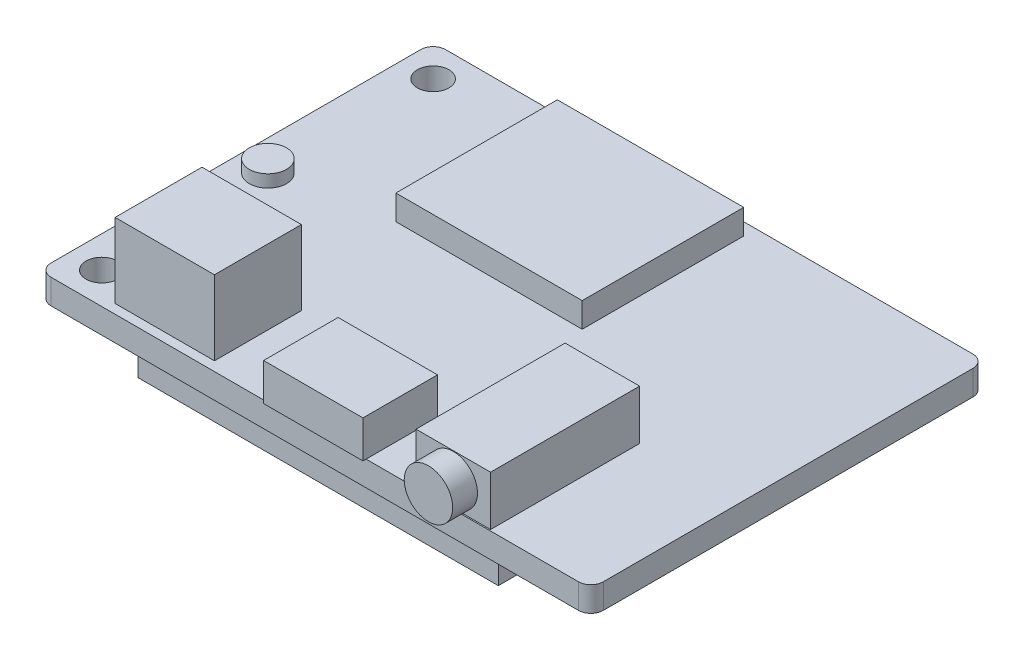
from build123d import *

# Parameters (mm, degrees)
SKETCH1_W           = 44.45
SKETCH1_H           = 31.75
BOSS_EXTRUDE1_DEPTH = 2
SKETCH2_R           = 1.27
CUT_EXTRUDE1_DEPTH  = 2
FILLET1_R           = 1
FILLET2_R           = 1
FILLET3_R           = 1
FILLET4_R           = 1
SKETCH3_W           = 8
SKETCH3_H           = 7
BOSS_EXTRUDE2_DEPTH = 6
SKETCH4_W           = 8
SKETCH4_H           = 6
BOSS_EXTRUDE3_DEPTH = 3
SKETCH5_W           = 6
SKETCH5_H           = 12
BOSS_EXTRUDE4_DEPTH = 4
SKETCH6_R           = 1.95
BOSS_EXTRUDE5_DEPTH = 2
SKETCH7_R           = 1.5
BOSS_EXTRUDE6_DEPTH = 1
SKETCH9_W           = 15
SKETCH9_H           = 13
BOSS_EXTRUDE7_DEPTH = 2
SKETCH10_W          = 29
SKETCH10_H          = 17
BOSS_EXTRUDE8_DEPTH = 2.5


with BuildPart() as part:
    # Sketch1 → Boss-Extrude1 (new body)
    with BuildSketch(Plane(origin=(0, 0, 0), x_dir=(1, 0, 0), z_dir=(0, 1, 0))):
        Rectangle(SKETCH1_W, SKETCH1_H)
    extrude(amount=BOSS_EXTRUDE1_DEPTH)

    # Sketch2 → Cut-Extrude1 (cut)
    with BuildSketch(Plane(origin=(0, 2, 0), x_dir=(1, 0, 0), z_dir=(0, 1, 0))):
        with Locations((-19.685, -13.335)):
            Circle(SKETCH2_R)
        with Locations((-19.685, 13.335)):
            Circle(SKETCH2_R)
    extrude(amount=-CUT_EXTRUDE1_DEPTH, mode=Mode.SUBTRACT)

    # Fillet1
    fillet1_edges = [part.edges().sort_by_distance(p)[0] for p in [
        (-22.225, 1, -15.875),
    ]]
    fillet(fillet1_edges, radius=FILLET1_R)

    # Fillet2
    fillet2_edges = [part.edges().sort_by_distance(p)[0] for p in [
        (-22.225, 1, 15.875),
    ]]
    fillet(fillet2_edges, radius=FILLET2_R)

    # Fillet3
    fillet3_edges = [part.edges().sort_by_distance(p)[0] for p in [
        (22.225, 1, -15.875),
    ]]
    fillet(fillet3_edges, radius=FILLET3_R)

    # Fillet4
    fillet4_edges = [part.edges().sort_by_distance(p)[0] for p in [
        (22.225, 1, 15.875),
    ]]
    fillet(fillet4_edges, radius=FILLET4_R)

    # Sketch3 → Boss-Extrude2 (add)
    with BuildSketch(Plane(origin=(0, 2, 0), x_dir=(1, 0, 0), z_dir=(0, 1, 0))):
        with Locations((-12.827, -11.625)):
            Rectangle(SKETCH3_W, SKETCH3_H)
    extrude(amount=BOSS_EXTRUDE2_DEPTH)

    # Sketch4 → Boss-Extrude3 (add)
    with BuildSketch(Plane(origin=(0, 2, 0), x_dir=(1, 0, 0), z_dir=(0, 1, 0))):
        with Locations((0.127, -13.125)):
            Rectangle(SKETCH4_W, SKETCH4_H)
    extrude(amount=BOSS_EXTRUDE3_DEPTH)

    # Sketch5 → Boss-Extrude4 (add)
    with BuildSketch(Plane(origin=(0, 2, 0), x_dir=(1, 0, 0), z_dir=(0, 1, 0))):
        with Locations((11.049, -9.775)):
            Rectangle(SKETCH5_W, SKETCH5_H)
    extrude(amount=BOSS_EXTRUDE4_DEPTH)

    # Sketch6 → Boss-Extrude5 (add)
    with BuildSketch(Plane.XY.offset(15.775)):
        with Locations((11.049, 4)):
            Circle(SKETCH6_R)
    extrude(amount=BOSS_EXTRUDE5_DEPTH)

    # Sketch7 → Boss-Extrude6 (add)
    with BuildSketch(Plane(origin=(0, 2, 0), x_dir=(1, 0, 0), z_dir=(0, 1, 0))):
        with Locations((-19.775, 0.125)):
            Circle(SKETCH7_R)
    extrude(amount=BOSS_EXTRUDE6_DEPTH)

    # Sketch9 → Boss-Extrude7 (add)
    with BuildSketch(Plane(origin=(0, 2, 0), x_dir=(1, 0, 0), z_dir=(0, 1, 0))):
        with Locations((-3.725, 8.375)):
            Rectangle(SKETCH9_W, SKETCH9_H)
    extrude(amount=BOSS_EXTRUDE7_DEPTH)

    # Sketch10 → Boss-Extrude8 (add)
    with BuildSketch(Plane.XZ):
        with Locations((-0.725, 6.375)):
            Rectangle(SKETCH10_W, SKETCH10_H)
    extrude(amount=BOSS_EXTRUDE8_DEPTH)


solid = part.part
